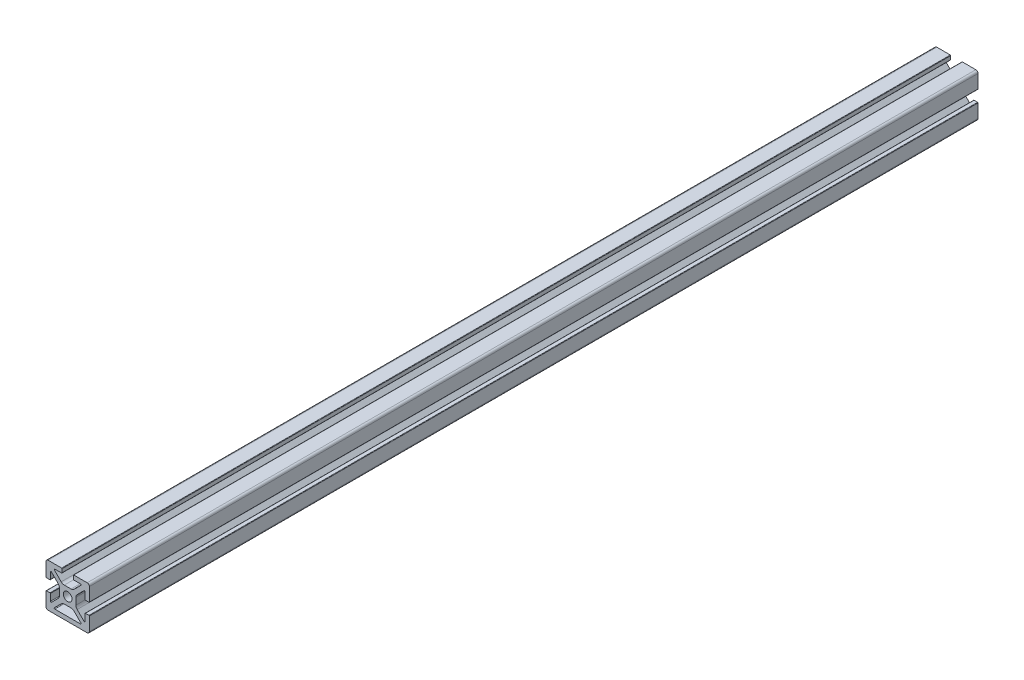
from build123d import *

# Parameters (mm, degrees)
BOSS_EXTRUDE1_DEPTH = 260.35
FILLET2_R           = 0.254
FILLET1_R           = 1.27
SKETCH5_W           = 7.112
SKETCH5_H           = 2.54
BOSS_EXTRUDE2_DEPTH = 520.7


with BuildPart() as part:
    # Sketch3 → Boss-Extrude1 (new body, symmetric)
    with BuildSketch(Plane.XY):
        with BuildLine():
            Line((-12.7, 12.7), (-1.796051224, 1.796051224))
            ThreePointArc((-1.796051224, 1.796051224), (-0.972015918, 2.346654013), (0, 2.54))
            Line((0, 2.54), (0, 4.826))
            Line((0, 4.826), (-1.977846327, 4.826))
            ThreePointArc((-1.977846327, 4.826), (-2.949862246, 5.019345987), (-3.773897552, 5.569948776))
            Line((-3.773897552, 5.569948776), (-7.772528286, 9.56857951))
            ThreePointArc((-7.772528286, 9.56857951), (-7.847628361, 9.946133082), (-7.527553898, 10.16))
            Line((-7.527553898, 10.16), (-3.302, 10.16))
            Line((-3.302, 10.16), (-3.302, 12.7))
            Line((-3.302, 12.7), (-12.7, 12.7))
        make_face()
    extrude(amount=BOSS_EXTRUDE1_DEPTH, both=True)

    # Fillet2
    fillet2_edges = [part.edges().sort_by_distance(p)[0] for p in [
        (-3.302, 12.7, 0),
        (-3.302, 10.16, 0),
    ]]
    fillet(fillet2_edges, radius=FILLET2_R)

    # Mirror1: part across plane


with BuildPart() as part_1:
    add(part.part)
    add(part.part.mirror(Plane(origin=(0, 0, 260.35), x_dir=(0, 0, 1), z_dir=(0.707106781, 0.707106781, 0))))

    # Fillet1
    fillet1_edges = [part_1.edges().sort_by_distance(p)[0] for p in [
        (-12.7, 12.7, 0),
    ]]
    fillet(fillet1_edges, radius=FILLET1_R)

    # Mirror2: part across plane


with BuildPart() as part_2:
    add(part_1.part)
    add(part_1.part.mirror(Plane(origin=(0, 0, 260.35), x_dir=(0, 0, 1), z_dir=(0, 1, 0))))

    # Mirror5: part across plane


with BuildPart() as part_3:
    add(part_2.part)
    add(part_2.part.mirror(Plane(origin=(0, 0, 260.35), x_dir=(0, 0, 1), z_dir=(-1, 0, 0))))

    # Sketch5 → Boss-Extrude2 (add, through all)
    with BuildSketch(Plane.XY.offset(260.35)):
        with Locations((0, -11.43)):
            Rectangle(SKETCH5_W, SKETCH5_H)
    extrude(amount=-BOSS_EXTRUDE2_DEPTH)


solid = part_3.part
